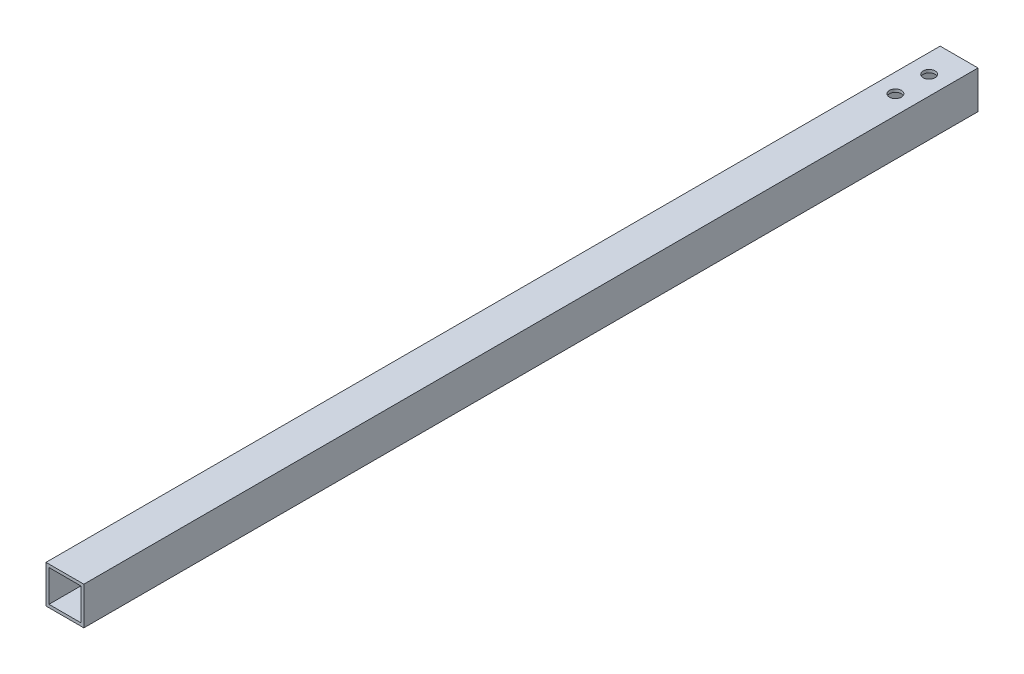
from build123d import *

# Parameters (mm, degrees)
SKETCH1_W           = 12.7
SKETCH1_H           = 12.7
BOSS_EXTRUDE1_DEPTH = 300
SHELL18_T           = -1
SKETCH2_R           = 2
CUT_EXTRUDE1_DEPTH  = 30
SKETCH3_R           = 2
CUT_EXTRUDE2_DEPTH  = 20


with BuildPart() as part:
    # Sketch1 → Boss-Extrude1 (new body)
    with BuildSketch(Plane.XY):
        with Locations((0.433911759, -1.30095226)):
            Rectangle(SKETCH1_W, SKETCH1_H)
    extrude(amount=BOSS_EXTRUDE1_DEPTH)

    # Shell18
    shell18_openings = [part.faces().sort_by_distance(p)[0] for p in [
        (0.433911759, -1.30095226, 300),
        (0.433911759, -1.30095226, 0),
    ]]
    offset(amount=SHELL18_T, openings=shell18_openings, kind=Kind.INTERSECTION)

    # Sketch2 → Cut-Extrude1 (cut)
    with BuildSketch(Plane(origin=(0, 5.04904774, 0), x_dir=(1, 0, 0), z_dir=(0, 1, 0))):
        with Locations((0.433911759, -10.040040702)):
            Circle(SKETCH2_R)
        with Locations((0.433911759, -21.34849815)):
            Circle(SKETCH2_R)
    extrude(amount=-CUT_EXTRUDE1_DEPTH, mode=Mode.SUBTRACT)

    # Sketch3 → Cut-Extrude2 (cut)
    with BuildSketch(Plane(origin=(0, 5.04904774, 0), x_dir=(1, 0, 0), z_dir=(0, 1, 0))):
        with Locations((0.433911759, -336)):
            Circle(SKETCH3_R)
        with Locations((0.433911759, -316)):
            Circle(SKETCH3_R)
    extrude(amount=-CUT_EXTRUDE2_DEPTH, mode=Mode.SUBTRACT)


solid = part.part
